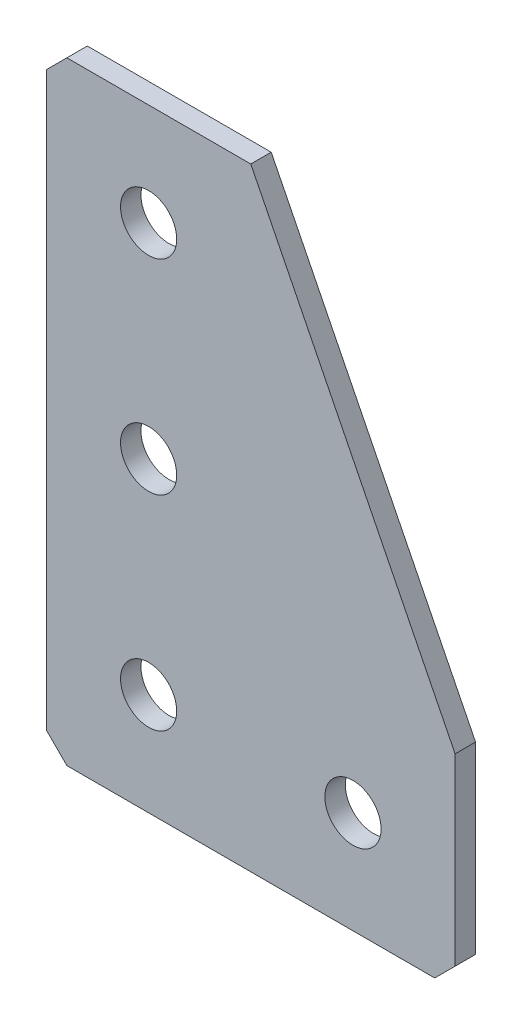
from build123d import *

# Parameters (mm, degrees)
EXTRUDE_1_DEPTH   = 2
HOLE_WIZARD_M51_D = 5.5
CHAMFER_1_SIZE    = 2


with BuildPart() as part:
    # Эскиз1 → Бобышка-Вытянуть1 (new body)
    with BuildSketch(Plane(origin=(0, 0, 0), x_dir=(1, 0, 0), z_dir=(0, 0, -1))):
        Polygon((0, 0), (0, 60), (40, 60), (40, 40), (20, 0), align=None)
    extrude(amount=EXTRUDE_1_DEPTH)

    # Отверстие с зазором M51 (through all)
    with Locations(Plane(origin=(0, 0, -2), x_dir=(1, 0, 0), z_dir=(0, 0, -1))):
        with Locations((30, 50), (10, 50), (10, 30), (10, 10)):
            Hole(HOLE_WIZARD_M51_D / 2)

    # Фаска1
    chamfer_1_edges = [part.edges().sort_by_distance(p)[0] for p in [
        (0, 0, -1),
        (0, -60, -1),
        (40, -60, -1),
    ]]
    chamfer(chamfer_1_edges, length=CHAMFER_1_SIZE)


solid = part.part
